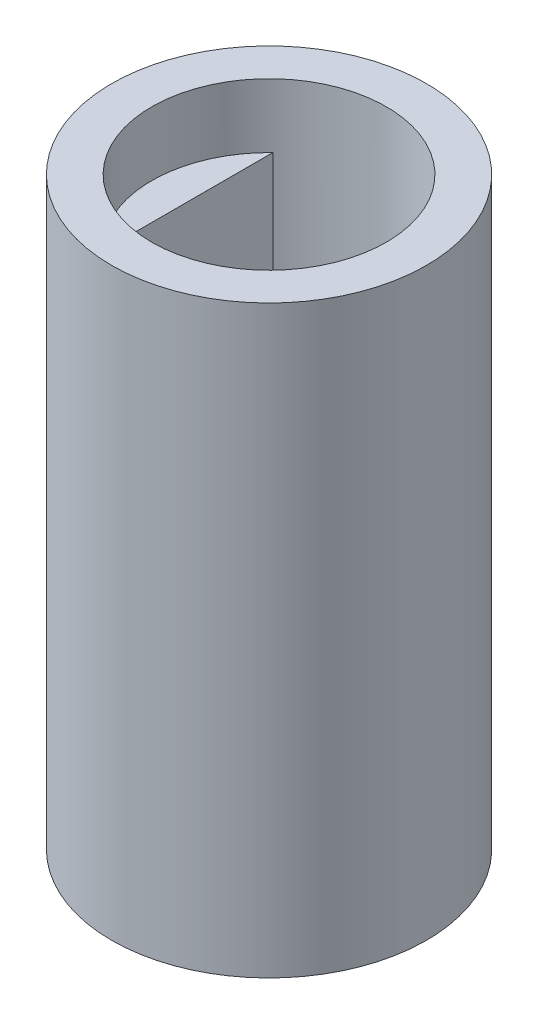
from build123d import *

# Parameters (mm, degrees)
SKETCH4_R           = 3.69
BOSS_EXTRUDE2_DEPTH = 13.7
SKETCH5_R           = 2.75
CUT_EXTRUDE2_DEPTH  = 1.5
CUT_EXTRUDE3_DEPTH  = 7.2
SKETCH7_W           = 1.9
SKETCH7_H           = 1.5
SKETCH7_H_2         = 1.9
SKETCH7_W_2         = 1.5
CUT_EXTRUDE5_DEPTH  = 5
FILLET1_R           = 0.75
FILLET2_R           = 0.75
FILLET3_R           = 0.75
FILLET4_R           = 0.75


with BuildPart() as part:
    # Sketch4 → Boss-Extrude2 (new body)
    with BuildSketch(Plane(origin=(0, 0, 0), x_dir=(1, 0, 0), z_dir=(0, 1, 0))):
        with Locations((-30.556065381, -14.685726519)):
            Circle(SKETCH4_R)
    extrude(amount=BOSS_EXTRUDE2_DEPTH)

    # Sketch5 → Cut-Extrude2 (cut)
    with BuildSketch(Plane(origin=(0, 13.7, 0), x_dir=(1, 0, 0), z_dir=(0, 1, 0))):
        with Locations((-30.556065381, -14.685726519)):
            Circle(SKETCH5_R)
    extrude(amount=-CUT_EXTRUDE2_DEPTH, mode=Mode.SUBTRACT)

    # Sketch6 → Cut-Extrude3 (cut)
    with BuildSketch(Plane(origin=(0, 12.2, 0), x_dir=(1, 0, 0), z_dir=(0, 1, 0))):
        with BuildLine():
            ThreePointArc((-32.456065381, -16.673816054), (-30.556065381, -17.435726519), (-28.656065381, -16.673816054))
            Line((-28.656065381, -16.673816054), (-28.656065381, -12.697636984))
            ThreePointArc((-28.656065381, -12.697636984), (-30.556065381, -11.935726519), (-32.456065381, -12.697636984))
            Line((-32.456065381, -12.697636984), (-32.456065381, -16.673816054))
        make_face()
    extrude(amount=-CUT_EXTRUDE3_DEPTH, mode=Mode.SUBTRACT)

    # Sketch7 → Cut-Extrude5 (cut)
    with BuildSketch(Plane(origin=(0, 0, 0), x_dir=(-1, 0, 0), z_dir=(0, -1, 0))):
        with Locations((30.556065381, -16.385726519)):
            Rectangle(SKETCH7_W, SKETCH7_H)
        with Locations((30.556065381, -14.685726519)):
            Rectangle(SKETCH7_W, SKETCH7_H_2)
        with Locations((28.856065381, -14.685726519)):
            Rectangle(SKETCH7_W_2, SKETCH7_H_2)
        with Locations((32.256065381, -14.685726519)):
            Rectangle(SKETCH7_W_2, SKETCH7_H_2)
        with Locations((30.556065381, -12.985726519)):
            Rectangle(SKETCH7_W, SKETCH7_H)
    extrude(amount=-CUT_EXTRUDE5_DEPTH, mode=Mode.SUBTRACT)

    # Fillet1
    fillet1_edges = [part.edges().sort_by_distance(p)[0] for p in [
        (-31.506065381, 2.5, 15.635726519),
    ]]
    fillet(fillet1_edges, radius=FILLET1_R)

    # Fillet2
    fillet2_edges = [part.edges().sort_by_distance(p)[0] for p in [
        (-29.606065381, 2.5, 13.735726519),
    ]]
    fillet(fillet2_edges, radius=FILLET2_R)

    # Fillet3
    fillet3_edges = [part.edges().sort_by_distance(p)[0] for p in [
        (-29.606065381, 2.5, 15.635726519),
    ]]
    fillet(fillet3_edges, radius=FILLET3_R)

    # Fillet4
    fillet4_edges = [part.edges().sort_by_distance(p)[0] for p in [
        (-31.506065381, 2.5, 13.735726519),
    ]]
    fillet(fillet4_edges, radius=FILLET4_R)


solid = part.part
